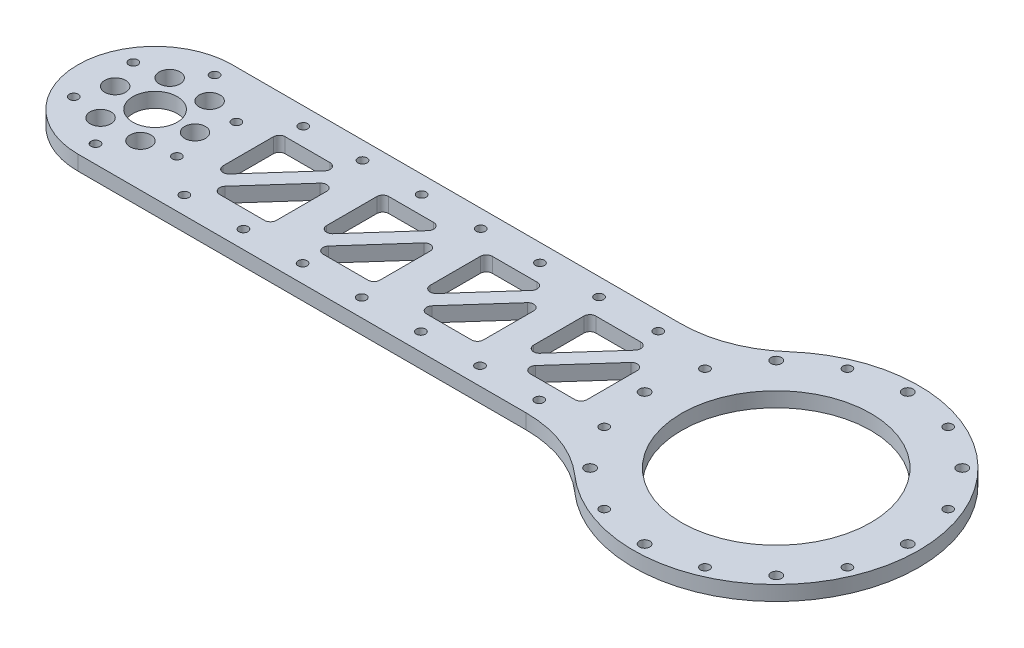
from build123d import *

# Parameters (mm, degrees)
EXTRUDE_1_DEPTH                = 5
SKETCH_2_R                     = 1.525
CUT_EXTRUDE_1_DEPTH            = 6
SKETCH_3_R                     = 48.25
EXTRUDE_2_DEPTH                = 5
SKETCH_4_R                     = 32
CUT_EXTRUDE_2_DEPTH            = 6
FILLET_1_R                     = 40
SKETCH_9_R                     = 7.5
CUT_EXTRUDE_7_DEPTH            = 6
SKETCH_10_R                    = 1.775
CUT_EXTRUDE_8_DEPTH            = 6
SKETCH_11_R                    = 1.525
CUT_EXTRUDE_9_DEPTH            = 6
SKETCH_15_R                    = 1.525
CUT_EXTRUDE_10_DEPTH           = 6
SKETCH_16_R                    = 1.525
SKETCH_16_R_2                  = 3.525
CUT_EXTRUDE_11_DEPTH           = 6
SKETCH_18_R                    = 1.525
CUT_EXTRUDE_13_DEPTH           = 6
CUT_EXTRUDE_14_DEPTH           = 6
FILLET_2_R                     = 2
PATTERN_LINEAR_1_COUNT         = 4
PATTERN_LINEAR_1_PITCH         = 35
FILLET_2_OF_PATTERN_LINEAR_1_R = 2


with BuildPart() as part:
    # 草图1 → 凸台-拉伸1 (new body)
    with BuildSketch(Plane(origin=(0, 0, 0), x_dir=(1, 0, 0), z_dir=(0, 1, 0))):
        with BuildLine():
            ThreePointArc((-78.875, 0), (-86.526835342, -18.473164658), (-105, -26.125))
            Line((-105, -26.125), (105, -26.125))
            Line((105, -26.125), (105, 26.125))
            Line((105, 26.125), (-105, 26.125))
            ThreePointArc((-105, 26.125), (-86.526835342, 18.473164658), (-78.875, 0))
        make_face()
        with BuildLine():
            ThreePointArc((-105, 26.125), (-131.125, 0), (-105, -26.125))
            Line((-105, -26.125), (-105, 26.125))
        make_face()
        with BuildLine():
            Line((-105, 26.125), (-105, -26.125))
            ThreePointArc((-105, -26.125), (-86.526835342, -18.473164658), (-78.875, 0))
            ThreePointArc((-78.875, 0), (-86.526835342, 18.473164658), (-105, 26.125))
        make_face()
    extrude(amount=EXTRUDE_1_DEPTH)

    # 草图2 → 切除-拉伸1 (cut, through all)
    with BuildSketch(Plane(origin=(0, 5, 0), x_dir=(1, 0, 0), z_dir=(0, 1, 0))):
        with Locations((-91.5, 0)):
            Circle(SKETCH_2_R)
        with Locations((-98.25, -11.691342951)):
            Circle(SKETCH_2_R)
        with Locations((-111.75, -11.691342951)):
            Circle(SKETCH_2_R)
        with Locations((-118.5, 0)):
            Circle(SKETCH_2_R)
        with Locations((-111.75, 11.691342951)):
            Circle(SKETCH_2_R)
        with Locations((-98.25, 11.691342951)):
            Circle(SKETCH_2_R)
    extrude(amount=-CUT_EXTRUDE_1_DEPTH, mode=Mode.SUBTRACT)

    # 草图3 → 凸台-拉伸2 (add)
    with BuildSketch(Plane(origin=(0, 5, 0), x_dir=(1, 0, 0), z_dir=(0, 1, 0))):
        with Locations((105, 0)):
            Circle(SKETCH_3_R)
    extrude(amount=-EXTRUDE_2_DEPTH)

    # 草图4 → 切除-拉伸2 (cut, through all)
    with BuildSketch(Plane(origin=(0, 5, 0), x_dir=(1, 0, 0), z_dir=(0, 1, 0))):
        with Locations((105, 0)):
            Circle(SKETCH_4_R)
    extrude(amount=-CUT_EXTRUDE_2_DEPTH, mode=Mode.SUBTRACT)

    # 圆角1
    fillet_1_edges = [part.edges().sort_by_distance(p)[0] for p in [
        (64.43465919, 2.5, 26.125),
        (64.43465919, 2.5, -26.125),
    ]]
    fillet(fillet_1_edges, radius=FILLET_1_R)

    # 草图9 → 切除-拉伸7 (cut, through all)
    with BuildSketch(Plane(origin=(0, 5, 0), x_dir=(1, 0, 0), z_dir=(0, 1, 0))):
        with Locations((-105, 0)):
            Circle(SKETCH_9_R)
    extrude(amount=-CUT_EXTRUDE_7_DEPTH, mode=Mode.SUBTRACT)

    # 草图10 → 切除-拉伸8 (cut, through all)
    with BuildSketch(Plane(origin=(0, 5, 0), x_dir=(1, 0, 0), z_dir=(0, 1, 0))):
        with Locations((73.533748237, 31.466251763)):
            Circle(SKETCH_10_R)
        with Locations((60.5, 0)):
            Circle(SKETCH_10_R)
        with Locations((73.533748237, -31.466251763)):
            Circle(SKETCH_10_R)
        with Locations((136.466251763, -31.466251763)):
            Circle(SKETCH_10_R)
        with Locations((136.466251763, 31.466251763)):
            Circle(SKETCH_10_R)
        with Locations((149.5, 0)):
            Circle(SKETCH_10_R)
        with Locations((105, -44.5)):
            Circle(SKETCH_10_R)
        with Locations((105, 44.5)):
            Circle(SKETCH_10_R)
    extrude(amount=-CUT_EXTRUDE_8_DEPTH, mode=Mode.SUBTRACT)

    # 草图11 → 切除-拉伸9 (cut, through all)
    with BuildSketch(Plane(origin=(0, 5, 0), x_dir=(1, 0, 0), z_dir=(0, 1, 0))):
        with Locations((122.02941274, 41.112639197)):
            Circle(SKETCH_11_R)
        with Locations((146.112639197, 17.02941274)):
            Circle(SKETCH_11_R)
        with Locations((146.112639197, -17.02941274)):
            Circle(SKETCH_11_R)
        with Locations((122.02941274, -41.112639197)):
            Circle(SKETCH_11_R)
        with Locations((87.97058726, -41.112639197)):
            Circle(SKETCH_11_R)
        with Locations((63.887360803, -17.02941274)):
            Circle(SKETCH_11_R)
        with Locations((63.887360803, 17.02941274)):
            Circle(SKETCH_11_R)
        with Locations((87.97058726, 41.112639197)):
            Circle(SKETCH_11_R)
    extrude(amount=-CUT_EXTRUDE_9_DEPTH, mode=Mode.SUBTRACT)

    # 草图15 → 切除-拉伸10 (cut, through all)
    with BuildSketch(Plane(origin=(0, 5, 0), x_dir=(1, 0, 0), z_dir=(0, 1, 0))):
        with Locations((-122.428761251, 10.0625)):
            Circle(SKETCH_15_R)
        with Locations((-105, 20.125)):
            Circle(SKETCH_15_R)
        with Locations((-87.571238749, 10.0625)):
            Circle(SKETCH_15_R)
        with Locations((-87.571238749, -10.0625)):
            Circle(SKETCH_15_R)
        with Locations((-105, -20.125)):
            Circle(SKETCH_15_R)
        with Locations((-122.428761251, -10.0625)):
            Circle(SKETCH_15_R)
    extrude(amount=-CUT_EXTRUDE_10_DEPTH, mode=Mode.SUBTRACT)

    # 草图16 → 切除-拉伸11 (cut, through all)
    with BuildSketch(Plane(origin=(0, 5, 0), x_dir=(1, 0, 0), z_dir=(0, 1, 0))):
        with Locations((-111.75, 11.691342951)):
            Circle(SKETCH_16_R)
        with Locations((-111.75, 11.691342951)):
            Circle(SKETCH_16_R_2)
        with Locations((-111.75, 11.691342951)):
            Circle(SKETCH_16_R, mode=Mode.SUBTRACT)
        with Locations((-98.25, 11.691342951)):
            Circle(SKETCH_16_R_2)
        with Locations((-98.25, 11.691342951)):
            Circle(SKETCH_16_R, mode=Mode.SUBTRACT)
        with Locations((-98.25, 11.691342951)):
            Circle(SKETCH_16_R)
        with Locations((-91.5, 0)):
            Circle(SKETCH_16_R)
        with Locations((-91.5, 0)):
            Circle(SKETCH_16_R_2)
        with Locations((-91.5, 0)):
            Circle(SKETCH_16_R, mode=Mode.SUBTRACT)
        with Locations((-98.25, -11.691342951)):
            Circle(SKETCH_16_R_2)
        with Locations((-98.25, -11.691342951)):
            Circle(SKETCH_16_R, mode=Mode.SUBTRACT)
        with Locations((-111.75, -11.691342951)):
            Circle(SKETCH_16_R_2)
        with Locations((-111.75, -11.691342951)):
            Circle(SKETCH_16_R, mode=Mode.SUBTRACT)
        with Locations((-111.75, -11.691342951)):
            Circle(SKETCH_16_R)
        with Locations((-118.5, 0)):
            Circle(SKETCH_16_R_2)
        with Locations((-118.5, 0)):
            Circle(SKETCH_16_R, mode=Mode.SUBTRACT)
        with Locations((-118.5, 0)):
            Circle(SKETCH_16_R)
    extrude(amount=-CUT_EXTRUDE_11_DEPTH, mode=Mode.SUBTRACT)

    # 草图18 → 切除-拉伸13 (cut, through all)
    with BuildSketch(Plane(origin=(0, 5, 0), x_dir=(1, 0, 0), z_dir=(0, 1, 0))):
        with Locations((45, 20.125)):
            Circle(SKETCH_18_R)
        with Locations((25, 20.125)):
            Circle(SKETCH_18_R)
        with Locations((5, 20.125)):
            Circle(SKETCH_18_R)
        with Locations((-15, 20.125)):
            Circle(SKETCH_18_R)
        with Locations((-35, 20.125)):
            Circle(SKETCH_18_R)
        with Locations((-55, 20.125)):
            Circle(SKETCH_18_R)
        with Locations((-75, 20.125)):
            Circle(SKETCH_18_R)
    cut_extrude_13 = extrude(amount=-CUT_EXTRUDE_13_DEPTH, mode=Mode.SUBTRACT)

    # 镜向1: 切除-拉伸13 across plane
    add(cut_extrude_13.mirror(Plane.XY), mode=Mode.SUBTRACT)

    # 草图19 → 切除-拉伸14 (cut, through all)
    with BuildSketch(Plane(origin=(0, 5, 0), x_dir=(1, 0, 0), z_dir=(0, 1, 0))):
        Polygon((-77, 14), (-77, -10.246335124), (-55.351486496, 14), align=None)
        Polygon((-52, 10.246335124), (-73.648513504, -14), (-52, -14), align=None)
    cut_extrude_14 = extrude(amount=-CUT_EXTRUDE_14_DEPTH, mode=Mode.SUBTRACT)

    # 圆角2
    fillet_2_edges = [part.edges().sort_by_distance(p)[0] for p in [
        (-52, 2.5, 14),
        (-73.648513504, 2.5, 14),
        (-52, 2.5, -10.246335124),
        (-77, 2.5, 10.246335124),
        (-77, 2.5, -14),
        (-55.351486496, 2.5, -14),
    ]]
    fillet(fillet_2_edges, radius=FILLET_2_R)

    # 阵列(线性)1: 切除-拉伸14 ×4
    with Locations(*[(i * PATTERN_LINEAR_1_PITCH, 0, 0) for i in range(1, PATTERN_LINEAR_1_COUNT)]):
        add(cut_extrude_14, mode=Mode.SUBTRACT)

    # 圆角2 of 阵列(线性)1
    fillet_2_of_pattern_linear_1_edges = [part.edges().sort_by_distance(p)[0] for p in [
        (-17, 2.5, 14),
        (-38.648513504, 2.5, 14),
        (-17, 2.5, -10.246335124),
        (-42, 2.5, 10.246335124),
        (-42, 2.5, -14),
        (-20.351486496, 2.5, -14),
        (18, 2.5, 14),
        (-3.648513504, 2.5, 14),
        (18, 2.5, -10.246335124),
        (-7, 2.5, 10.246335124),
        (-7, 2.5, -14),
        (14.648513504, 2.5, -14),
        (53, 2.5, 14),
        (31.351486496, 2.5, 14),
        (53, 2.5, -10.246335124),
        (28, 2.5, 10.246335124),
        (28, 2.5, -14),
        (49.648513504, 2.5, -14),
    ]]
    fillet(fillet_2_of_pattern_linear_1_edges, radius=FILLET_2_OF_PATTERN_LINEAR_1_R)


solid = part.part
